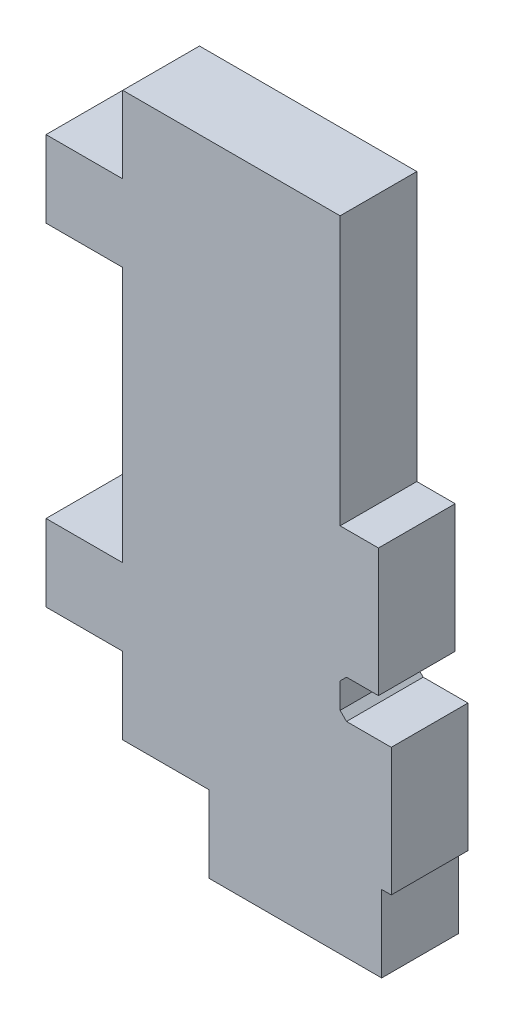
from build123d import *

# Parameters (mm, degrees)
SKETCH1_W           = 10.5
SKETCH1_H           = 22
BOSS_EXTRUDE1_DEPTH = 3
SKETCH2_W           = 6.75
SKETCH2_H           = 3
BOSS_EXTRUDE2_DEPTH = 3
SKETCH3_W           = 3
SKETCH3_H           = 3
BOSS_EXTRUDE3_DEPTH = 3
SKETCH4_W           = 2
SKETCH4_H           = 1.5
CUT_EXTRUDE1_DEPTH  = 3
SKETCH5_W           = 2
SKETCH5_H           = 10.5
CUT_EXTRUDE2_DEPTH  = 3
CHAMFER1_SIZE       = 0.25
CHAMFER2_SIZE       = 0.25
SKETCH6_W           = 3
SKETCH6_H           = 5
CUT_EXTRUDE3_DEPTH  = 0.5


with BuildPart() as part:
    # Sketch1 → Boss-Extrude1 (new body)
    with BuildSketch(Plane.XY):
        with Locations((1.5, 0)):
            Rectangle(SKETCH1_W, SKETCH1_H)
    extrude(amount=BOSS_EXTRUDE1_DEPTH)

    # Sketch2 → Boss-Extrude2 (add)
    with BuildSketch(Plane.XZ.offset(11)):
        with Locations((3, 1.5)):
            Rectangle(SKETCH2_W, SKETCH2_H)
    extrude(amount=BOSS_EXTRUDE2_DEPTH)

    # Sketch3 → Boss-Extrude3 (add)
    with BuildSketch(Plane.ZY.offset(3.75)):
        with Locations((1.5, -6.5)):
            Rectangle(SKETCH3_W, SKETCH3_H)
        with Locations((1.5, 6.5)):
            Rectangle(SKETCH3_W, SKETCH3_H)
    extrude(amount=BOSS_EXTRUDE3_DEPTH)

    # Sketch4 → Cut-Extrude1 (cut)
    with BuildSketch(Plane.XY.offset(3)):
        with Locations((5.75, -5.25)):
            Rectangle(SKETCH4_W, SKETCH4_H)
    extrude(amount=-CUT_EXTRUDE1_DEPTH, mode=Mode.SUBTRACT)

    # Sketch5 → Cut-Extrude2 (cut)
    with BuildSketch(Plane.XY.offset(3)):
        with Locations((5.75, 5.75)):
            Rectangle(SKETCH5_W, SKETCH5_H)
    extrude(amount=-CUT_EXTRUDE2_DEPTH, mode=Mode.SUBTRACT)

    # Chamfer1
    chamfer1_edges = [part.edges().sort_by_distance(p)[0] for p in [
        (4.75, -4.5, 1.5),
    ]]
    chamfer(chamfer1_edges, length=CHAMFER1_SIZE)

    # Chamfer2
    chamfer2_edges = [part.edges().sort_by_distance(p)[0] for p in [
        (4.75, -6, 1.5),
    ]]
    chamfer(chamfer2_edges, length=CHAMFER2_SIZE)

    # Sketch6 → Cut-Extrude3 (cut)
    with BuildSketch(Plane(origin=(6.75, 0, 0), x_dir=(0, 0, -1), z_dir=(1, 0, 0))):
        with Locations((-1.5, -2)):
            Rectangle(SKETCH6_W, SKETCH6_H)
    extrude(amount=-CUT_EXTRUDE3_DEPTH, mode=Mode.SUBTRACT)


solid = part.part
